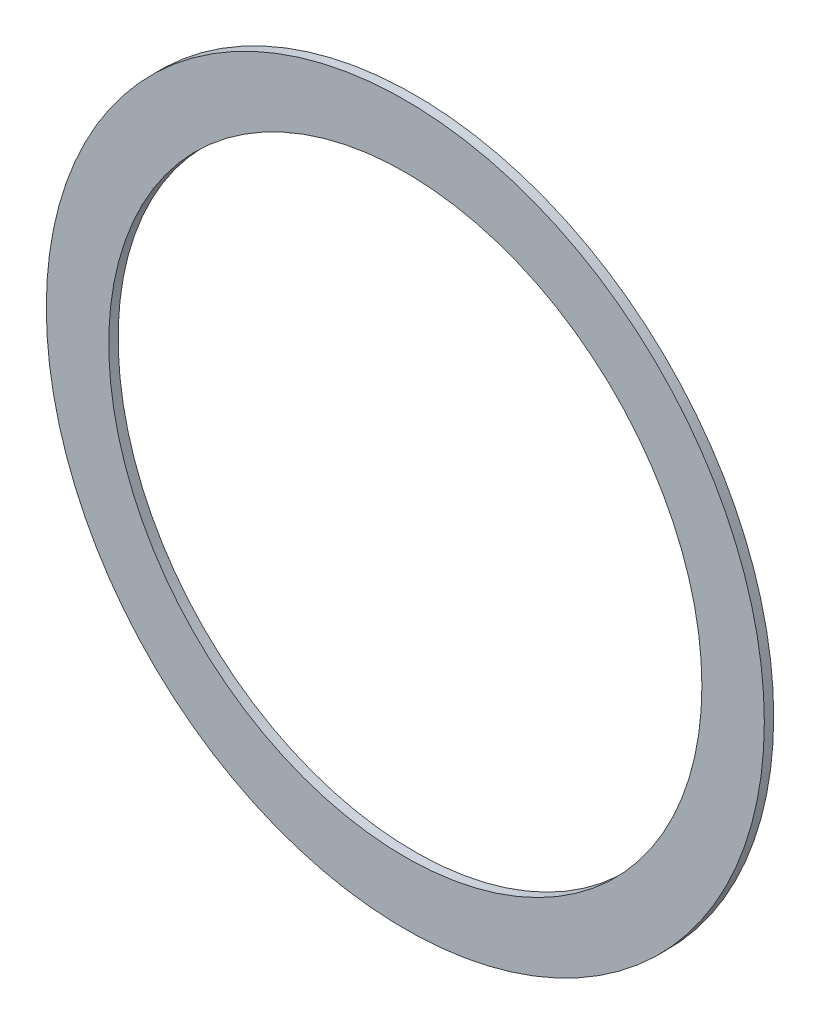
from build123d import *

# Parameters (mm, degrees)
CROQUIS1_R              = 115
CROQUIS1_R_2            = 95
SALIENTE_EXTRUIR1_DEPTH = 3


with BuildPart() as part:
    # Croquis1 → Saliente-Extruir1 (new body)
    with BuildSketch(Plane.XY):
        Circle(CROQUIS1_R)
        Circle(CROQUIS1_R_2, mode=Mode.SUBTRACT)
    extrude(amount=SALIENTE_EXTRUIR1_DEPTH)


solid = part.part
